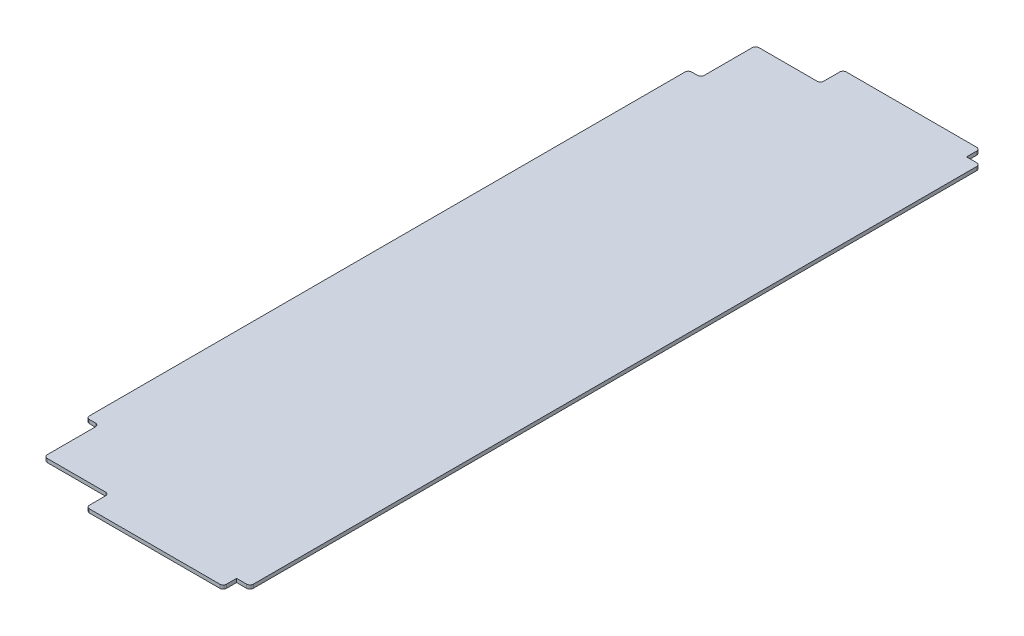
from build123d import *

# Parameters (mm, degrees)
SKETCH1_W           = 190.5
SKETCH1_H           = 609.6
BOSS_EXTRUDE1_DEPTH = 2.778125
SKETCH2_W           = 190.5
SKETCH2_H           = 17.78
CUT_EXTRUDE1_DEPTH  = 3.778125
SKETCH3_W           = 17.78
SKETCH3_H           = 574.04
CUT_EXTRUDE2_DEPTH  = 3.778125
SKETCH4_W           = 10.16
SKETCH4_H           = 10.16
CUT_EXTRUDE3_DEPTH  = 3.778125
FILLET1_R           = 2.54


with BuildPart() as part:
    # Sketch1 → Boss-Extrude1 (new body)
    with BuildSketch(Plane(origin=(0, 0, 0), x_dir=(1, 0, 0), z_dir=(0, 1, 0))):
        with Locations((95.25, 304.8)):
            Rectangle(SKETCH1_W, SKETCH1_H)
    extrude(amount=BOSS_EXTRUDE1_DEPTH)

    # Sketch2 → Cut-Extrude1 (cut, through all)
    with BuildSketch(Plane(origin=(0, 2.778125, 0), x_dir=(1, 0, 0), z_dir=(0, 1, 0))):
        with Locations((95.25, 8.89)):
            Rectangle(SKETCH2_W, SKETCH2_H)
        with Locations((95.25, 600.71)):
            Rectangle(SKETCH2_W, SKETCH2_H)
    extrude(amount=-CUT_EXTRUDE1_DEPTH, mode=Mode.SUBTRACT)

    # Sketch3 → Cut-Extrude2 (cut, through all)
    with BuildSketch(Plane(origin=(0, 2.778125, 0), x_dir=(1, 0, 0), z_dir=(0, 1, 0))):
        with Locations((8.89, 304.8)):
            Rectangle(SKETCH3_W, SKETCH3_H)
    extrude(amount=-CUT_EXTRUDE2_DEPTH, mode=Mode.SUBTRACT)

    # Sketch4 → Cut-Extrude3 (cut, through all)
    with BuildSketch(Plane(origin=(0, 2.778125, 0), x_dir=(1, 0, 0), z_dir=(0, 1, 0))):
        Polygon((17.78, 591.82), (76.454, 591.82), (76.454, 574.675), (27.305, 574.675), (27.305, 533.146), (17.78, 533.146), align=None)
        Polygon((17.78, 17.78), (76.454, 17.78), (76.454, 34.925), (27.305, 34.925), (27.305, 76.454), (17.78, 76.454), align=None)
        with Locations((185.42, 586.74)):
            Rectangle(SKETCH4_W, SKETCH4_H)
        with Locations((185.42, 22.86)):
            Rectangle(SKETCH4_W, SKETCH4_H)
    extrude(amount=-CUT_EXTRUDE3_DEPTH, mode=Mode.SUBTRACT)

    # Fillet1
    fillet1_edges = [part.edges().sort_by_distance(p)[0] for p in [
        (17.78, 1.3890625, -76.454),
        (27.305, 1.3890625, -76.454),
        (27.305, 1.3890625, -34.925),
        (76.454, 1.3890625, -34.925),
        (76.454, 1.3890625, -17.78),
        (190.5, 1.3890625, -581.66),
        (180.34, 1.3890625, -591.82),
        (190.5, 1.3890625, -27.94),
        (180.34, 1.3890625, -17.78),
        (17.78, 1.3890625, -533.146),
        (76.454, 1.3890625, -591.82),
        (76.454, 1.3890625, -574.675),
        (27.305, 1.3890625, -574.675),
        (27.305, 1.3890625, -533.146),
    ]]
    fillet(fillet1_edges, radius=FILLET1_R)


solid = part.part
